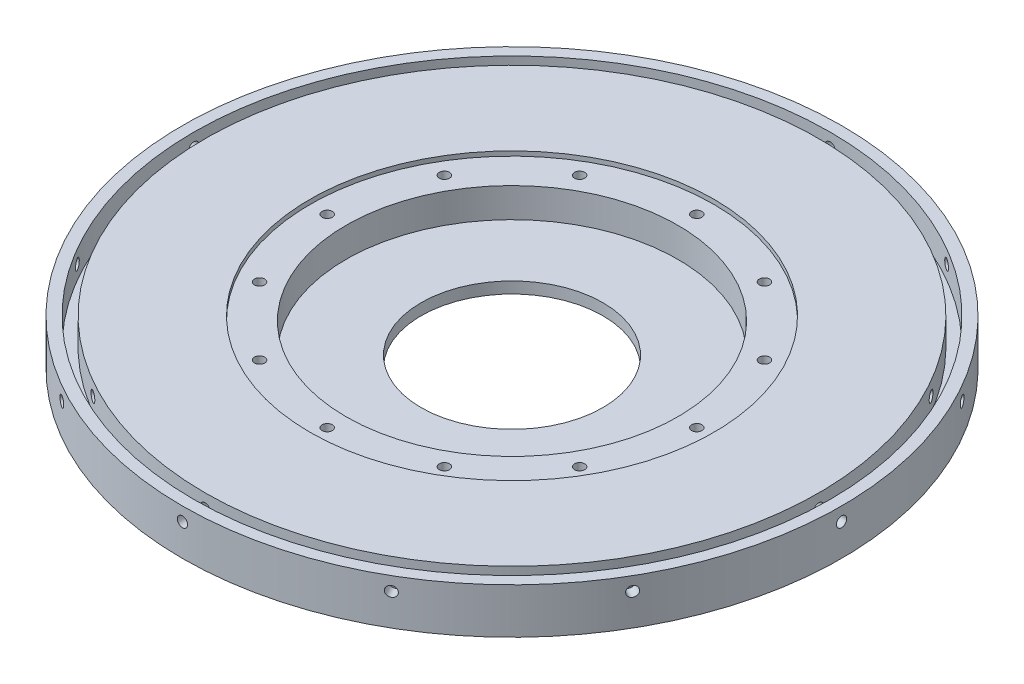
from build123d import *

# Parameters (mm, degrees)
SKETCH1_W           = 127.635
SKETCH1_H           = 127.635
BOSS_EXTRUDE1_DEPTH = 9.525
SKETCH13_R          = 92.075
BOSS_EXTRUDE2_DEPTH = 12.7
SKETCH5_R           = 46.355
CUT_EXTRUDE1_DEPTH  = 9.525
SKETCH11_R          = 1.4351
CUT_EXTRUDE3_DEPTH  = 13.7
CIRPATTERN1_COUNT   = 12
SKETCH12_R          = 56.41975
CUT_EXTRUDE4_DEPTH  = 1.27
SKETCH16_R          = 88.9
SKETCH16_R_2        = 85.725
CUT_EXTRUDE5_DEPTH  = 7.62
SKETCH17_R          = 1.4351
CUT_EXTRUDE6_DEPTH  = 15.24
CIRPATTERN2_COUNT   = 12
SKETCH19_R          = 25.4
CUT_EXTRUDE7_DEPTH  = 87.63


with BuildPart() as part:
    # Sketch1 → Boss-Extrude1 (new body)
    with BuildSketch(Plane(origin=(0, 0, 0), x_dir=(1, 0, 0), z_dir=(0, 1, 0))):
        with Locations((63.8175, 63.8175)):
            Rectangle(SKETCH1_W, SKETCH1_H)
    extrude(amount=BOSS_EXTRUDE1_DEPTH)

    # Sketch13 → Boss-Extrude2 (add)
    with BuildSketch(Plane(origin=(0, 9.525, 0), x_dir=(1, 0, 0), z_dir=(0, 1, 0))):
        with Locations((63.8175, 63.8175)):
            Circle(SKETCH13_R)
    extrude(amount=-BOSS_EXTRUDE2_DEPTH)

    # Sketch5 → Cut-Extrude1 (cut)
    with BuildSketch(Plane(origin=(0, 9.525, 0), x_dir=(1, 0, 0), z_dir=(0, 1, 0))):
        with Locations((63.8175, 63.8175)):
            Circle(SKETCH5_R)
    extrude(amount=-CUT_EXTRUDE1_DEPTH, mode=Mode.SUBTRACT)

    # Sketch11 → Cut-Extrude3 (cut, through all)
    with BuildSketch(Plane(origin=(0, 9.525, 0), x_dir=(1, 0, 0), z_dir=(0, 1, 0))):
        with Locations((63.8175, 115.443)):
            Circle(SKETCH11_R)
    cut_extrude3 = extrude(amount=-CUT_EXTRUDE3_DEPTH, mode=Mode.SUBTRACT)

    # CirPattern1: Cut-Extrude3 ×12 about axis
    cirpattern1_axis = Axis((63.8175, 0, -63.8175), (0, 1, 0))
    for i in range(1, CIRPATTERN1_COUNT):
        add(cut_extrude3.rotate(cirpattern1_axis, i * 360 / CIRPATTERN1_COUNT), mode=Mode.SUBTRACT)

    # Sketch12 → Cut-Extrude4 (cut)
    with BuildSketch(Plane(origin=(0, 9.525, 0), x_dir=(1, 0, 0), z_dir=(0, 1, 0))):
        with Locations((63.8175, 63.8175)):
            Circle(SKETCH12_R)
    extrude(amount=-CUT_EXTRUDE4_DEPTH, mode=Mode.SUBTRACT)

    # Sketch16 → Cut-Extrude5 (cut)
    with BuildSketch(Plane(origin=(0, 9.525, 0), x_dir=(1, 0, 0), z_dir=(0, 1, 0))):
        with Locations((63.8175, 63.8175)):
            Circle(SKETCH16_R)
        with Locations((63.8175, 63.8175)):
            Circle(SKETCH16_R_2, mode=Mode.SUBTRACT)
    extrude(amount=-CUT_EXTRUDE5_DEPTH, mode=Mode.SUBTRACT)

    # Sketch17 → Cut-Extrude6 (cut)
    with BuildSketch(Plane.XY.offset(28.2575)):
        with Locations((63.8175, 5.715)):
            Circle(SKETCH17_R)
    cut_extrude6 = extrude(amount=-CUT_EXTRUDE6_DEPTH, mode=Mode.SUBTRACT)

    # CirPattern2: Cut-Extrude6 ×12 about axis
    cirpattern2_axis = Axis((63.8175, 0, -63.8175), (0, 1, 0))
    for i in range(1, CIRPATTERN2_COUNT):
        add(cut_extrude6.rotate(cirpattern2_axis, i * 360 / CIRPATTERN2_COUNT), mode=Mode.SUBTRACT)

    # Sketch19 → Cut-Extrude7 (cut)
    with BuildSketch(Plane.XZ.offset(3.175)):
        with Locations((63.8175, -63.8175)):
            Circle(SKETCH19_R)
    extrude(amount=-CUT_EXTRUDE7_DEPTH, mode=Mode.SUBTRACT)


solid = part.part
